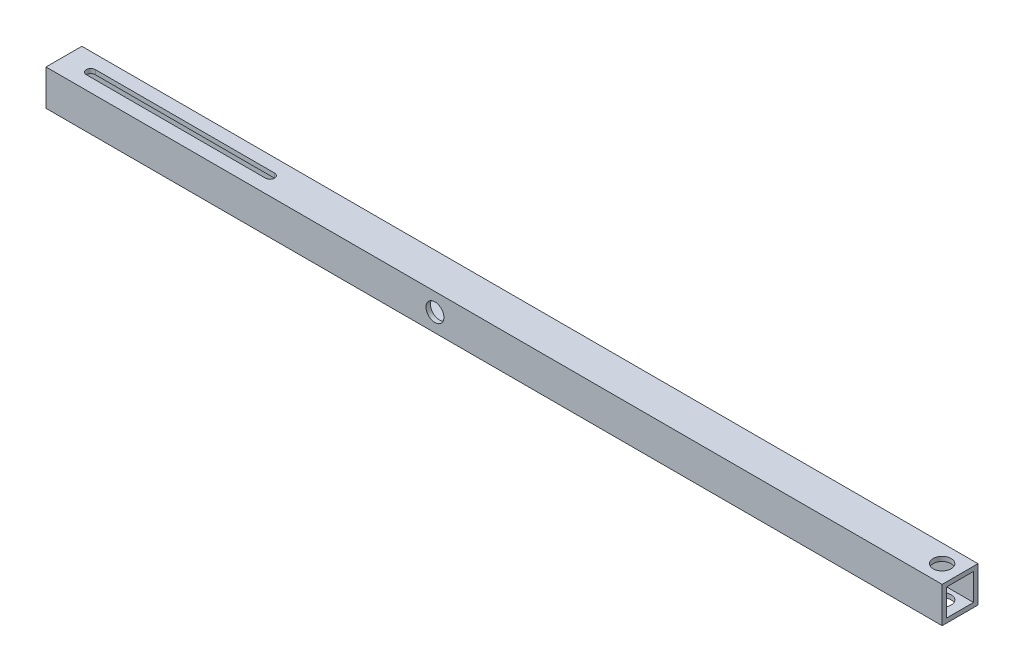
from build123d import *

# Parameters (mm, degrees)
SKETCH1_W           = 500
SKETCH1_H           = 20
BOSS_EXTRUDE1_DEPTH = 20
SKETCH6_R           = 5
CUT_EXTRUDE5_DEPTH  = 21
SKETCH8_W           = 15
SKETCH8_H           = 15
CUT_EXTRUDE7_DEPTH  = 501
CUT_EXTRUDE8_DEPTH  = 100
SKETCH10_R          = 5
CUT_EXTRUDE9_DEPTH  = 21


with BuildPart() as part:
    # Sketch1 → Boss-Extrude1 (new body)
    with BuildSketch(Plane(origin=(0, 0, 0), x_dir=(1, 0, 0), z_dir=(0, 1, 0))):
        Rectangle(SKETCH1_W, SKETCH1_H)
    extrude(amount=BOSS_EXTRUDE1_DEPTH)

    # Sketch6 → Cut-Extrude5 (cut, through all)
    with BuildSketch(Plane.XY.offset(10)):
        with Locations((-33, 10)):
            Circle(SKETCH6_R)
    extrude(amount=-CUT_EXTRUDE5_DEPTH, mode=Mode.SUBTRACT)

    # Sketch8 → Cut-Extrude7 (cut, through all)
    with BuildSketch(Plane.ZY.offset(250)):
        with Locations((0, 10)):
            Rectangle(SKETCH8_W, SKETCH8_H)
    extrude(amount=-CUT_EXTRUDE7_DEPTH, mode=Mode.SUBTRACT)

    # Sketch9 → Cut-Extrude8 (cut)
    with BuildSketch(Plane(origin=(0, 20, 0), x_dir=(1, 0, 0), z_dir=(0, 1, 0))):
        with BuildLine():
            Line((-235, 2.5), (-135, 2.5))
            ThreePointArc((-135, 2.5), (-132.5, 0), (-135, -2.5))
            Line((-135, -2.5), (-235, -2.5))
            ThreePointArc((-235, -2.5), (-237.5, 0), (-235, 2.5))
        make_face()
    extrude(amount=-CUT_EXTRUDE8_DEPTH, mode=Mode.SUBTRACT)

    # Sketch10 → Cut-Extrude9 (cut, through all)
    with BuildSketch(Plane(origin=(0, 20, 0), x_dir=(1, 0, 0), z_dir=(0, 1, 0))):
        with Locations((240, 0)):
            Circle(SKETCH10_R)
    extrude(amount=-CUT_EXTRUDE9_DEPTH, mode=Mode.SUBTRACT)


solid = part.part
